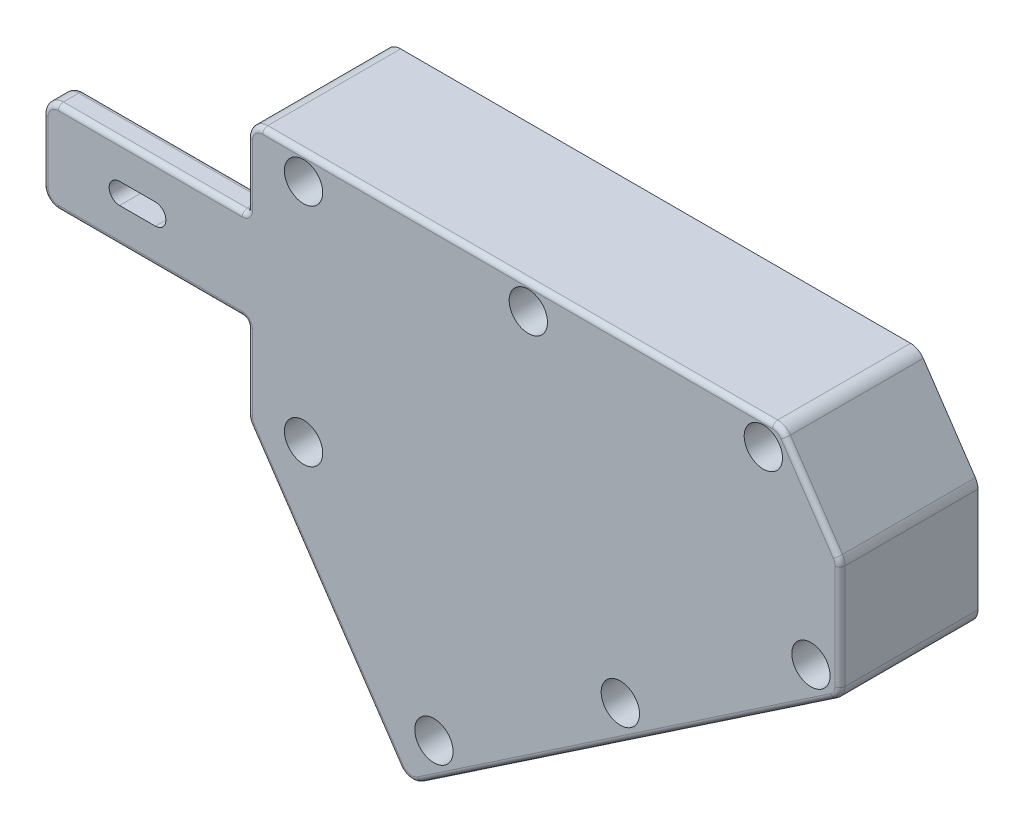
from build123d import *

# Parameters (mm, degrees)
SKETCH4_R           = 2.2500000000000013
SKETCH4_R_2         = 2.2500000000000027
SKETCH4_R_3         = 2.2499999999999964
SKETCH4_R_4         = 2.249999999999996
BOSS_EXTRUDE1_DEPTH = 25
CUT_EXTRUDE1_START  = -30
SKETCH5_R           = 15.874999999999952
CUT_EXTRUDE1_DEPTH  = 30
CUT_EXTRUDE2_START  = -35
SKETCH6_R           = 15.874999999999952
CUT_EXTRUDE2_DEPTH  = 35
SKETCH7_R           = 14.75000008942099
CUT_EXTRUDE3_DEPTH  = 3
SKETCH8_R           = 14.749999054525292
CUT_EXTRUDE4_DEPTH  = 3
CUT_EXTRUDE5_DEPTH  = 16
SKETCH10_R          = 15.04999999992957
CUT_EXTRUDE6_DEPTH  = 4
BOSS_EXTRUDE2_DEPTH = 5
CUT_EXTRUDE7_REACH  = 140.939
FILLET4_R           = 3
FILLET5_R           = 3
SKETCH14_R          = 3.750000000000006
SKETCH14_R_2        = 3.750000000000007
SKETCH14_R_3        = 3.7499999999999996
SKETCH14_R_4        = 3.7500000000000058
CUT_EXTRUDE8_DEPTH  = 7.5
FILLET7_R           = 1
BOSS_EXTRUDE4_DEPTH = 2
BOSS_EXTRUDE5_DEPTH = 2
BOSS_EXTRUDE6_DEPTH = 2
BOSS_EXTRUDE7_START = -2
BOSS_EXTRUDE7_DEPTH = 2
FILLET8_R           = 1


with BuildPart() as part:
    # Sketch4 → Boss-Extrude1 (new body)
    with BuildSketch(Plane.XY.offset(-1794.997599915682)):
        Polygon((0.00993873344056589, 24.992104512799955), (104.40790730051027, 24.992104512799955), (116.00993873344059, 7.7913855548794535), (116.00993873344058, -15.171815869987777), (31.38121525312008, -72.2546106269668), (0.00993873344057211, -25.74478052646954), align=None)
        with Locations((11.009938733413076, 20.000014462070865)):
            Circle(SKETCH4_R, mode=Mode.SUBTRACT)
        with Locations((55.0000235560205, 20.0000207563879)):
            Circle(SKETCH4_R_2, mode=Mode.SUBTRACT)
        with Locations((101.00032947766128, 20.000421303290455)):
            Circle(SKETCH4_R_3, mode=Mode.SUBTRACT)
        with Locations((110.31298743881767, -12.232428015251282)):
            Circle(SKETCH4_R_4, mode=Mode.SUBTRACT)
        with Locations((73.00631721020957, -37.39600782393461)):
            Circle(SKETCH4_R_3, mode=Mode.SUBTRACT)
        with Locations((36.52747936466516, -62.00134443268738)):
            Circle(SKETCH4_R_2, mode=Mode.SUBTRACT)
        with Locations((11.009938733413076, -24.170034680366825)):
            Circle(SKETCH4_R, mode=Mode.SUBTRACT)
    extrude(amount=BOSS_EXTRUDE1_DEPTH)

    # Sketch5 → Cut-Extrude1 (cut)
    with BuildSketch(Plane.ZY.offset(-0.00993873344056895).offset(CUT_EXTRUDE1_START)):
        with Locations((-1794.997599915682, 0)):
            Circle(SKETCH5_R)
    extrude(amount=CUT_EXTRUDE1_DEPTH, mode=Mode.SUBTRACT)

    # Sketch6 → Cut-Extrude2 (cut)
    with BuildSketch(Plane(origin=(-11.928241497495174, -8.045700481013716, 0), x_dir=(0, 0, 1), z_dir=(-0.829037572555043, -0.5591929034707451, 0)).offset(CUT_EXTRUDE2_START)):
        with Locations((-1794.997599915682, -50.32735299672014)):
            Circle(SKETCH6_R)
    extrude(amount=CUT_EXTRUDE2_DEPTH, mode=Mode.SUBTRACT)

    # Sketch7 → Cut-Extrude3 (cut)
    with BuildSketch(Plane.ZY.offset(-30.009938733440574)):
        with Locations((-1794.997599915682, 0)):
            Circle(SKETCH7_R)
    extrude(amount=-CUT_EXTRUDE3_DEPTH, mode=Mode.SUBTRACT)

    # Sketch8 → Cut-Extrude4 (cut)
    with BuildSketch(Plane(origin=(17.08807354193135, 11.526051140462371, 0), x_dir=(0, 0, 1), z_dir=(-0.829037572555043, -0.5591929034707452, 0))):
        with Locations((-1794.997599915682, -50.32735299672015)):
            Circle(SKETCH8_R)
    extrude(amount=-CUT_EXTRUDE4_DEPTH, mode=Mode.SUBTRACT)

    # Sketch9 → Cut-Extrude5 (cut)
    with BuildSketch(Plane(origin=(0, 0, -1794.997599915682), x_dir=(-1, 0, 0), z_dir=(0, 0, -1))):
        Polygon((-32.999999821186066, 15.500039814543918), (-85.26117632239622, 15.50003981454392), (-94.59442246724795, 21.795393829033166), (-111.93202827604188, -3.903038277997192), (-56.38395812017689, -41.37068469228828), (-38.93396078781694, -15.49999974668026), (-32.999999821186066, -15.49999974668026), align=None)
    extrude(amount=-CUT_EXTRUDE5_DEPTH, mode=Mode.SUBTRACT)

    # Sketch10 → Cut-Extrude6 (cut)
    with BuildSketch(Plane(origin=(0, 0, -1778.997599915682), x_dir=(-1, 0, 0), z_dir=(0, 0, -1))):
        with Locations((-89.98824773797764, -0.00789548721469649)):
            Circle(SKETCH10_R)
    extrude(amount=-CUT_EXTRUDE6_DEPTH, mode=Mode.SUBTRACT)

    # Sketch11 → Boss-Extrude2 (add)
    with BuildSketch(Plane.XY.offset(-1769.997599915682)):
        Polygon((0.00993873343757158, 9), (-39.99006126656244, 8.999999999999995), (-39.990061266562435, -9.000000000000005), (0.00993873343757209, -9.000000000000004), align=None)
    extrude(amount=-BOSS_EXTRUDE2_DEPTH)

    # Sketch12 → Cut-Extrude7 (cut, up to next)
    with BuildSketch(Plane.XY.offset(-1769.997599915682), mode=Mode.PRIVATE) as cut_extrude7_sk1:
        with BuildLine():
            Line((-17.990061266586913, -2.0578954871867152), (-24.990061266562424, -2.0578954872101294))
            ThreePointArc((-24.990061266562424, -2.0578954872101294), (-27.040061266609257, -0.00789548716329644), (-24.990061266562424, 2.0421045128835345))
            Line((-24.990061266562424, 2.0421045128835345), (-17.990061266586913, 2.0421045128367))
            ThreePointArc((-17.990061266586913, 2.0421045128367), (-15.940061266586913, -0.00789548718671546), (-17.990061266586913, -2.0578954871867152))
        make_face()
    cut_extrude7_tool1 = extrude(cut_extrude7_sk1.sketch, amount=-CUT_EXTRUDE7_REACH, mode=Mode.PRIVATE) & part.part
    add(cut_extrude7_tool1.solids().sort_by_distance((-21.490061, -0.007895, -1769.9976))[0], mode=Mode.SUBTRACT)

    # Fillet4
    fillet4_edges = [part.edges().sort_by_distance(p)[0] for p in [
        (0.00993873344056589, 24.992104512799955, -1782.497599915682),
        (104.40790730051027, 24.992104512799955, -1782.497599915682),
        (116.00993873344059, 7.7913855548794535, -1782.497599915682),
        (116.00993873344058, -15.171815869987777, -1782.497599915682),
        (31.38121525312008, -72.2546106269668, -1782.497599915682),
        (0.00993873344057211, -25.74478052646954, -1782.497599915682),
    ]]
    fillet(fillet4_edges, radius=FILLET4_R)

    # Fillet5
    fillet5_edges = [part.edges().sort_by_distance(p)[0] for p in [
        (-39.990061266562435, -9.000000000000005, -1772.497599915682),
        (-39.99006126656244, 8.999999999999995, -1772.497599915682),
    ]]
    fillet(fillet5_edges, radius=FILLET5_R)

    # Sketch14 → Cut-Extrude8 (cut)
    with BuildSketch(Plane.XY.offset(-1769.997599915682)):
        with Locations((110.31298743881767, -12.232428015251282)):
            Circle(SKETCH14_R)
        with Locations((73.00631721020957, -37.39600782393461)):
            Circle(SKETCH14_R_2)
        with Locations((36.52747936466516, -62.00134443268738)):
            Circle(SKETCH14_R_2)
        with Locations((11.009938733413076, -24.170034680366825)):
            Circle(SKETCH14_R_3)
        with Locations((11.009938733413076, 20.000014462070865)):
            Circle(SKETCH14_R_3)
        with Locations((55.0000235560205, 20.0000207563879)):
            Circle(SKETCH14_R_4)
        with Locations((101.00032947766128, 20.000421303290455)):
            Circle(SKETCH14_R_4)
    extrude(amount=-CUT_EXTRUDE8_DEPTH, mode=Mode.SUBTRACT)

    # Fillet7
    fillet7_edges = [part.edges().sort_by_distance(p)[0] for p in [
        (0.00993873343757183, -1.78e-15, -1774.997599915682),
        (0.00993873343757158, 9, -1772.497599915682),
        (0.00993873343757209, -9.000000000000004, -1772.497599915682),
        (-18.490061266562435, 8.999999999999998, -1774.997599915682),
        (-39.990061266562435, -5.33e-15, -1774.997599915682),
        (-18.49006126656243, -9.000000000000004, -1774.997599915682),
        (-39.11138161012208, -8.121320343559647, -1774.997599915682),
        (-39.11138161012209, 8.121320343559638, -1774.997599915682),
    ]]
    fillet(fillet7_edges, radius=FILLET7_R)

    # Sketch15 → Boss-Extrude4 (add)
    with BuildSketch(Plane(origin=(0, 0, -1794.997599915682), x_dir=(-1, 0, 0), z_dir=(0, 0, -1))):
        with BuildLine():
            Line((-8.9953449512499, -35.4896097712826), (-7.337269806139812, -36.607995578224084))
            Line((-7.337269806139812, -36.607995578224084), (-0.522826015775444, -26.505167192505805))
            ThreePointArc((-0.522826015775444, -26.505167192505805), (-0.1410244655514652, -25.704703596261776), (-0.009938733440572, -24.82758848209357))
            Line((-0.009938733440572, -24.82758848209357), (-0.00993873344057511, -15.874999999999952))
            Line((-0.00993873344057511, -15.874999999999952), (-2.009938733440575, -15.874999999999952))
            Line((-2.009938733440575, -15.874999999999952), (-2.0099387334405723, -24.82758848209357))
            ThreePointArc((-2.0099387334405723, -24.82758848209357), (-2.0536339774775376, -25.119960186816307), (-2.1809011608855307, -25.386781385564316))
            Line((-2.1809011608855307, -25.386781385564316), (-8.9953449512499, -35.4896097712826))
        make_face()
    extrude(amount=BOSS_EXTRUDE4_DEPTH)

    # Sketch17 → Boss-Extrude5 (add)
    with BuildSketch(Plane(origin=(0, 0, -1794.997599915682), x_dir=(-1, 0, 0), z_dir=(0, 0, -1))):
        with BuildLine():
            Line((-25.091644491335906, -62.92993850684661), (-29.703636542707837, -69.76749790930165))
            ThreePointArc((-29.703636542707837, -69.76749790930165), (-31.6183222742433, -71.03480074923243), (-33.86832797078518, -70.57703191655457))
            Line((-33.86832797078518, -70.57703191655457), (-114.68751744385281, -16.063800292668468))
            ThreePointArc((-114.68751744385281, -16.063800292668468), (-115.65878151201736, -14.985102263361018), (-116.00993873344058, -13.57668757500334))
            Line((-116.00993873344058, -13.57668757500334), (-116.00993873344059, 6.8741935105034715))
            ThreePointArc((-116.00993873344059, 6.8741935105034715), (-115.8788530013297, 7.751308624671679), (-115.49705145110572, 8.551772220915705))
            Line((-115.49705145110572, 8.551772220915705), (-105.29989172319095, 23.6696832232122))
            ThreePointArc((-105.29989172319095, 23.6696832232122), (-104.2211936938835, 24.640947291376737), (-102.81277900552584, 24.992104512799955))
            Line((-102.81277900552584, 24.992104512799955), (-3.0099387334405665, 24.992104512799955))
            ThreePointArc((-3.0099387334405665, 24.992104512799955), (-0.8886183898809237, 24.1134248563596), (-0.00993873344056626, 21.99210451279996))
            Line((-0.00993873344056626, 21.99210451279996), (-0.00993873344056701, 15.874999999999952))
            Line((-0.00993873344056701, 15.874999999999952), (-2.009938733440567, 15.874999999999952))
            Line((-2.009938733440567, 15.874999999999952), (-2.009938733440566, 21.99210451279996))
            ThreePointArc((-2.009938733440566, 21.99210451279996), (-2.3028319522540186, 22.699211293986505), (-3.0099387334405665, 22.99210451279996))
            Line((-3.0099387334405665, 22.99210451279996), (-102.81277900552584, 22.992104512799955))
            ThreePointArc((-102.81277900552584, 22.992104512799955), (-103.28225056831172, 22.87505210565888), (-103.64181657808088, 22.551297416270703))
            Line((-103.64181657808088, 22.551297416270703), (-113.83897630599564, 7.4333864139742145))
            ThreePointArc((-113.83897630599564, 7.4333864139742145), (-113.96624348940364, 7.166565215226207), (-114.00993873344059, 6.874193510503473))
            Line((-114.00993873344059, 6.874193510503473), (-114.00993873344058, -13.576687575003339))
            ThreePointArc((-114.00993873344058, -13.576687575003339), (-113.8928863262995, -14.046159137789234), (-113.56913163691132, -14.405725147558387))
            Line((-113.56913163691132, -14.405725147558387), (-32.74994216384368, -68.9189567714445))
            ThreePointArc((-32.74994216384368, -68.9189567714445), (-31.999940264996386, -69.0715463823371), (-31.36171168781791, -68.64911210236018))
            Line((-31.36171168781791, -68.64911210236018), (-26.74971963644599, -61.81155269990512))
            Line((-26.74971963644599, -61.81155269990512), (-25.091644491335906, -62.92993850684661))
        make_face()
    extrude(amount=BOSS_EXTRUDE5_DEPTH)

    # Sketch20 → Boss-Extrude6 (add)
    with BuildSketch(Plane(origin=(-11.928241497495174, -8.045700481013716, 0), x_dir=(0, 0, 1), z_dir=(-0.829037572555043, -0.5591929034707451, 0))):
        with BuildLine():
            Line((-1796.997599915682, -32.56458370522732), (-1796.997599915682, -34.5788313656413))
            ThreePointArc((-1796.997599915682, -34.5788313656413), (-1779.1225978219331, -50.32734531066272), (-1796.997599915682, -66.07585925568414))
            Line((-1796.997599915682, -66.07585925568414), (-1796.997599915682, -68.09010691609812))
            ThreePointArc((-1796.997599915682, -68.09010691609812), (-1777.1225978219331, -50.32734531066272), (-1796.997599915682, -32.56458370522732))
        make_face()
    extrude(amount=-BOSS_EXTRUDE6_DEPTH)

    # Sketch21 → Boss-Extrude7 (add)
    with BuildSketch(Plane.ZY.offset(-0.00993873344056895).offset(BOSS_EXTRUDE7_START)):
        with BuildLine():
            Line((-1796.997599915682, 16.933411053952273), (-1796.997599915682, 15.74851183445599))
            ThreePointArc((-1796.997599915682, 15.74851183445599), (-1779.122599915682, -3.4e-16), (-1796.997599915682, -15.74851183445599))
            Line((-1796.997599915682, -15.74851183445599), (-1796.997599915682, -16.933411053952273))
            ThreePointArc((-1796.997599915682, -16.933411053952273), (-1777.946488224003, -3.4e-16), (-1796.997599915682, 16.933411053952273))
        make_face()
    extrude(amount=BOSS_EXTRUDE7_DEPTH)

    # Fillet8
    fillet8_edges = [part.edges().sort_by_distance(p)[0] for p in [
        (74.27792270731901, -43.32041610461151, -1769.997599915682),
        (15.113231279241639, -48.13633255090372, -1769.997599915682),
        (0.009938733440567, 15.996052256399977, -1769.997599915682),
        (116.00993873344059, -3.35124703224995, -1769.997599915682),
        (110.39847158714835, 16.110727722063938, -1769.997599915682),
        (52.91135886948321, 24.992104512799955, -1769.997599915682),
        (115.65878151201736, -14.985102263361027, -1769.997599915682),
        (115.87885300132972, 7.7513086246716645, -1769.997599915682),
        (104.22119369388352, 24.640947291376737, -1769.997599915682),
        (0.8886183898809241, 24.113424856359597, -1769.997599915682),
        (0.14102446555145587, -25.70470359626175, -1769.997599915682),
        (31.61832227424332, -71.03480074923242, -1769.997599915682),
        (-39.990061266562435, -5.33e-15, -1769.997599915682),
        (-18.99006126656094, -9.000000000000004, -1769.997599915682),
        (-39.11138161012208, -8.121320343559647, -1769.997599915682),
        (-39.11138161012209, 8.121320343559638, -1769.997599915682),
        (-18.99006126656094, 8.999999999999998, -1769.997599915682),
        (0.00993873344057109, -17.413794241046777, -1769.997599915682),
        (-0.2829544853728818, -9.292893218813456, -1769.997599915682),
        (-0.28295448537288437, 9.292893218813454, -1769.997599915682),
    ]]
    fillet(fillet8_edges, radius=FILLET8_R)


solid = part.part
